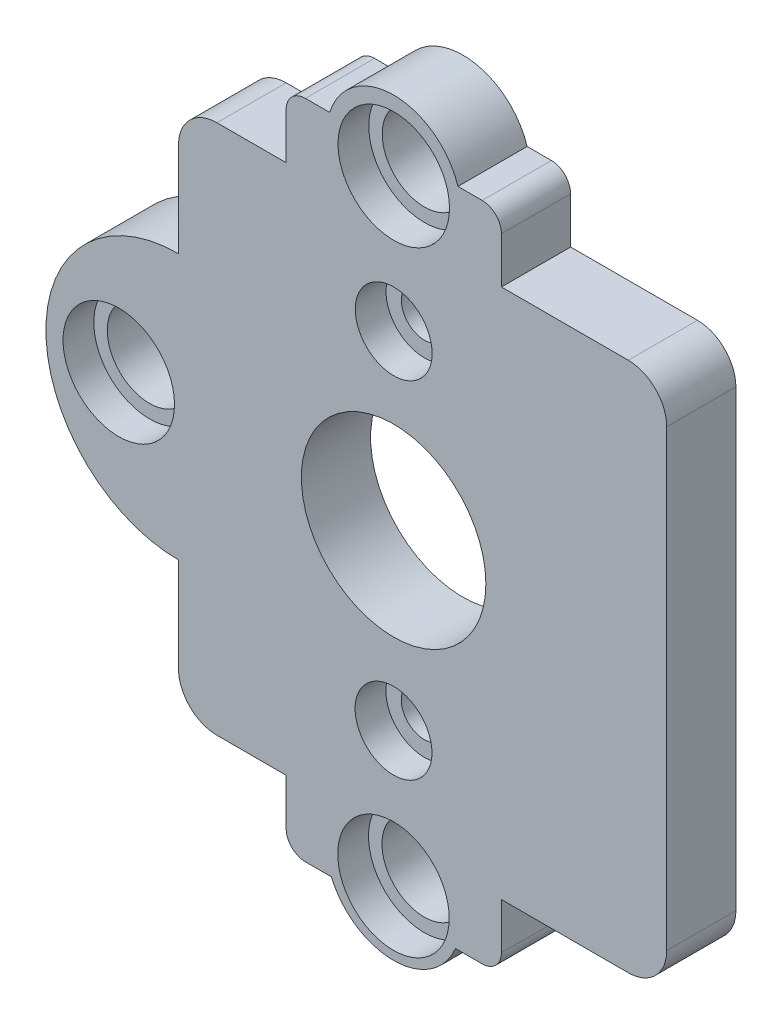
from build123d import *

# Parameters (mm, degrees)
BODY_DEPTH                      = 0.9
SIDE_EXTENDER_2_R               = 1.75
SIDE_EXTENDER_DEPTH             = 1.8
CENTER_EXTERN_W                 = 3
CENTER_EXTERN_H                 = 13.8
EXTENDER_CENTER_DEPTH           = 1.8
HOLES_R                         = 1.1
HOLES_R_2                       = 0.6
SCREW_HOLES_DEPTH               = 1.8
SHAFT_HOLE_R                    = 2.4
MOTOR_SHAFT_DEPTH               = 1.8
SKIZZE6_R                       = 1
SKIZZE6_R_2                     = 1.45
SCHNITT_LINEAR_AUSTRAGEN5_DEPTH = 0.8
VERRUNDUNG1_R                   = 1
VERRUNDUNG2_R                   = 0.5


with BuildPart() as part:
    # body 2 → body (new body, symmetric)
    with BuildSketch(Plane.XY):
        Polygon((0, 16.193693694), (-2.8, 16.193693694), (-2.8, 14.493693694), (-5.6, 14.493693694), (-5.6, 0.693693694), (-2.8, 0.693693694), (-2.8, -1.006306306), (0, -1.006306306), (2.8, -1.006306306), (2.8, 0.693693694), (5.6, 0.693693694), (5.6, 14.493693694), (2.8, 14.493693694), (2.8, 16.193693694), align=None)
    extrude(amount=BODY_DEPTH, both=True)

    # side_extender 2 → side-extender (add)
    with BuildSketch(Plane.XY.offset(0.9)):
        with Locations((0, 15.667972906)):
            Circle(SIDE_EXTENDER_2_R)
        with Locations((-0.0089251, -0.332027094)):
            Circle(SIDE_EXTENDER_2_R)
    extrude(amount=-SIDE_EXTENDER_DEPTH)

    # center-extern → Extender-center (add)
    with BuildSketch(Plane.XY.offset(0.9)):
        with BuildLine():
            Line((-5.6, 11.043693694), (-5.6, 4.143693694))
            ThreePointArc((-5.6, 4.143693694), (-9.05, 7.593693694), (-5.6, 11.043693694))
        make_face()
        with Locations((5.6, 7.593693694)):
            Rectangle(CENTER_EXTERN_W, CENTER_EXTERN_H)
    extrude(amount=-EXTENDER_CENTER_DEPTH)

    # holes → screw-holes (cut)
    with BuildSketch(Plane.XY.offset(0.9)):
        with Locations((-7.154497296, 7.593693694)):
            Circle(HOLES_R)
        with Locations((-0.000834968, 15.593693694)):
            Circle(HOLES_R)
        with Locations((-0.008158127, -0.406306306)):
            Circle(HOLES_R)
        with Locations((-0.002436909, 12.093693694)):
            Circle(HOLES_R_2)
        with Locations((-0.006556186, 3.093693694)):
            Circle(HOLES_R_2)
    extrude(amount=-SCREW_HOLES_DEPTH, mode=Mode.SUBTRACT)

    # shaft hole → motor shaft (cut)
    with BuildSketch(Plane.XY.offset(0.9)):
        with Locations((-0.00446255, 7.603703107)):
            Circle(SHAFT_HOLE_R)
    extrude(amount=-MOTOR_SHAFT_DEPTH, mode=Mode.SUBTRACT)

    # Skizze6 → Schnitt-Linear austragen5 (cut)
    with BuildSketch(Plane.XY.offset(0.9)):
        with Locations((-0.002436909, 12.093693694)):
            Circle(SKIZZE6_R)
        with Locations((-0.006556186, 3.093693694)):
            Circle(SKIZZE6_R)
        with Locations((-0.000834968, 15.593693694)):
            Circle(SKIZZE6_R_2)
        with Locations((-0.008158127, -0.406306306)):
            Circle(SKIZZE6_R_2)
        with Locations((-7.154497296, 7.593693694)):
            Circle(SKIZZE6_R_2)
    extrude(amount=-SCHNITT_LINEAR_AUSTRAGEN5_DEPTH, mode=Mode.SUBTRACT)

    # Verrundung1
    verrundung1_edges = [part.edges().sort_by_distance(p)[0] for p in [
        (-5.6, 0.693693694, 0),
        (-5.6, 14.493693694, 0),
        (7.1, 0.693693694, 0),
        (7.1, 14.493693694, 0),
    ]]
    fillet(verrundung1_edges, radius=VERRUNDUNG1_R)

    # Verrundung2
    verrundung2_edges = [part.edges().sort_by_distance(p)[0] for p in [
        (2.8, 16.193693694, 0),
        (2.8, -1.006306306, 0),
        (-2.8, -1.006306306, 0),
        (-2.8, 16.193693694, 0),
    ]]
    fillet(verrundung2_edges, radius=VERRUNDUNG2_R)


solid = part.part
